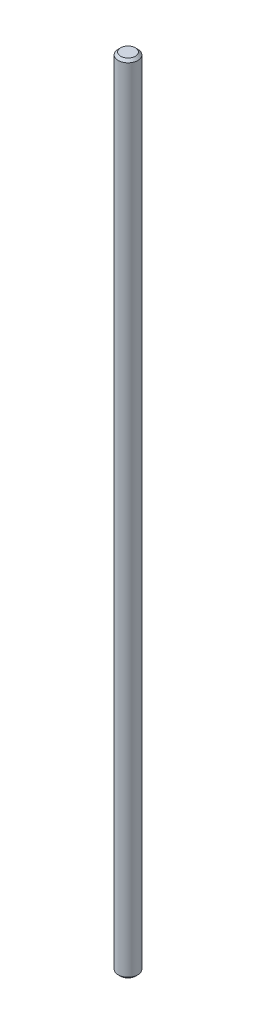
from build123d import *


with BuildPart() as part:
    # Sketch1 → Revolve1 (revolve)
    with BuildSketch(Plane(origin=(0, 0, 0), x_dir=(0, 0, -1), z_dir=(1, 0, 0))):
        Polygon((0, 0), (0, 325), (3, 325), (4, 324), (4, 0.927627121), (3.072372879, 0), align=None)
    revolve(axis=Axis((0, -514.881648805, 0), (0, 1, 0)))


solid = part.part
